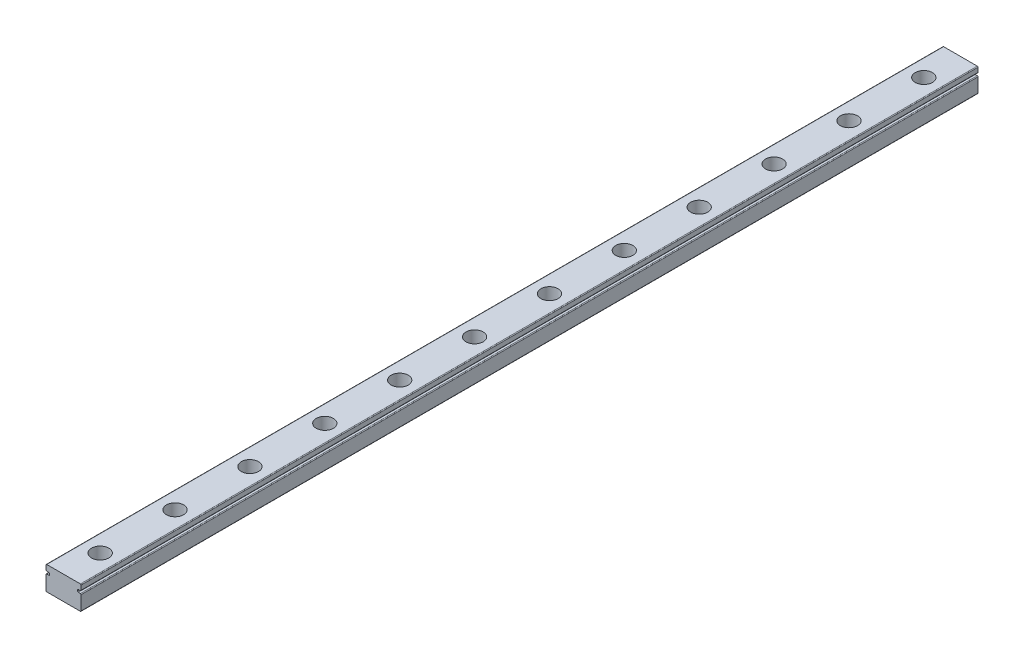
from build123d import *

# Parameters (mm, degrees)
BOSS_EXTRUDE1_DEPTH = 152.4
SKETCH2_R           = 2.921
CUT_EXTRUDE1_DEPTH  = 4.699
SKETCH4_R           = 1.905
CUT_EXTRUDE2_DEPTH  = 4.3782


with BuildPart() as part:
    # Sketch1 → Boss-Extrude1 (new body, symmetric)
    with BuildSketch(Plane.XY):
        with BuildLine():
            Line((-5.715, 2.0574), (-5.0419, 2.0574))
            ThreePointArc((-5.0419, 2.0574), (-4.862294878, 1.983005122), (-4.7879, 1.8034))
            Line((-4.7879, 1.8034), (-4.7879, 1.4732))
            ThreePointArc((-4.7879, 1.4732), (-4.862294878, 1.293594878), (-5.0419, 1.2192))
            Line((-5.0419, 1.2192), (-5.715, 1.2192))
            ThreePointArc((-5.715, 1.2192), (-5.894605122, 1.144805122), (-5.969, 0.9652))
            Line((-5.969, 0.9652), (-5.969, -3.7846))
            ThreePointArc((-5.969, -3.7846), (-5.894605122, -3.964205122), (-5.715, -4.0386))
            Line((-5.715, -4.0386), (5.715, -4.0386))
            ThreePointArc((5.715, -4.0386), (5.894605122, -3.964205122), (5.969, -3.7846))
            Line((5.969, -3.7846), (5.969, 0.9652))
            ThreePointArc((5.969, 0.9652), (5.894605122, 1.144805122), (5.715, 1.2192))
            Line((5.715, 1.2192), (5.0419, 1.2192))
            ThreePointArc((5.0419, 1.2192), (4.862294878, 1.293594878), (4.7879, 1.4732))
            Line((4.7879, 1.4732), (4.7879, 1.8034))
            ThreePointArc((4.7879, 1.8034), (4.862294878, 1.983005122), (5.0419, 2.0574))
            Line((5.0419, 2.0574), (5.715, 2.0574))
            ThreePointArc((5.715, 2.0574), (5.894605122, 2.131794878), (5.969, 2.3114))
            Line((5.969, 2.3114), (5.969, 3.7846))
            ThreePointArc((5.969, 3.7846), (5.894605122, 3.964205122), (5.715, 4.0386))
            Line((5.715, 4.0386), (-5.715, 4.0386))
            ThreePointArc((-5.715, 4.0386), (-5.894605122, 3.964205122), (-5.969, 3.7846))
            Line((-5.969, 3.7846), (-5.969, 2.3114))
            ThreePointArc((-5.969, 2.3114), (-5.894605122, 2.131794878), (-5.715, 2.0574))
        make_face()
    extrude(amount=BOSS_EXTRUDE1_DEPTH, both=True)

    # Sketch2 → Cut-Extrude1 (cut)
    with BuildSketch(Plane(origin=(0, 4.0386, 0), x_dir=(1, 0, 0), z_dir=(0, 1, 0))):
        with Locations((0, 139.954)):
            Circle(SKETCH2_R)
        with Locations((0, 114.507818182)):
            Circle(SKETCH2_R)
        with Locations((0, 89.061636364)):
            Circle(SKETCH2_R)
        with Locations((0, 63.615454545)):
            Circle(SKETCH2_R)
        with Locations((0, 38.169272727)):
            Circle(SKETCH2_R)
        with Locations((0, 12.723090909)):
            Circle(SKETCH2_R)
        with Locations((0, -12.723090909)):
            Circle(SKETCH2_R)
        with Locations((0, -38.169272727)):
            Circle(SKETCH2_R)
        with Locations((0, -63.615454545)):
            Circle(SKETCH2_R)
        with Locations((0, -89.061636364)):
            Circle(SKETCH2_R)
        with Locations((0, -114.507818182)):
            Circle(SKETCH2_R)
        with Locations((0, -139.954)):
            Circle(SKETCH2_R)
    extrude(amount=-CUT_EXTRUDE1_DEPTH, mode=Mode.SUBTRACT)

    # Sketch4 → Cut-Extrude2 (cut, through all)
    with BuildSketch(Plane(origin=(0, -0.6604, 0), x_dir=(1, 0, 0), z_dir=(0, 1, 0))):
        with Locations((0, 38.169272727)):
            Circle(SKETCH4_R)
        with Locations((0, 63.615454545)):
            Circle(SKETCH4_R)
        with Locations((0, 89.061636364)):
            Circle(SKETCH4_R)
        with Locations((0, 114.507818182)):
            Circle(SKETCH4_R)
        with Locations((0, 139.954)):
            Circle(SKETCH4_R)
        with Locations((0, -139.954)):
            Circle(SKETCH4_R)
        with Locations((0, -114.507818182)):
            Circle(SKETCH4_R)
        with Locations((0, -89.061636364)):
            Circle(SKETCH4_R)
        with Locations((0, -63.615454545)):
            Circle(SKETCH4_R)
        with Locations((0, -38.169272727)):
            Circle(SKETCH4_R)
        with Locations((0, -12.723090909)):
            Circle(SKETCH4_R)
        with Locations((0, 12.723090909)):
            Circle(SKETCH4_R)
    extrude(amount=-CUT_EXTRUDE2_DEPTH, mode=Mode.SUBTRACT)


solid = part.part
